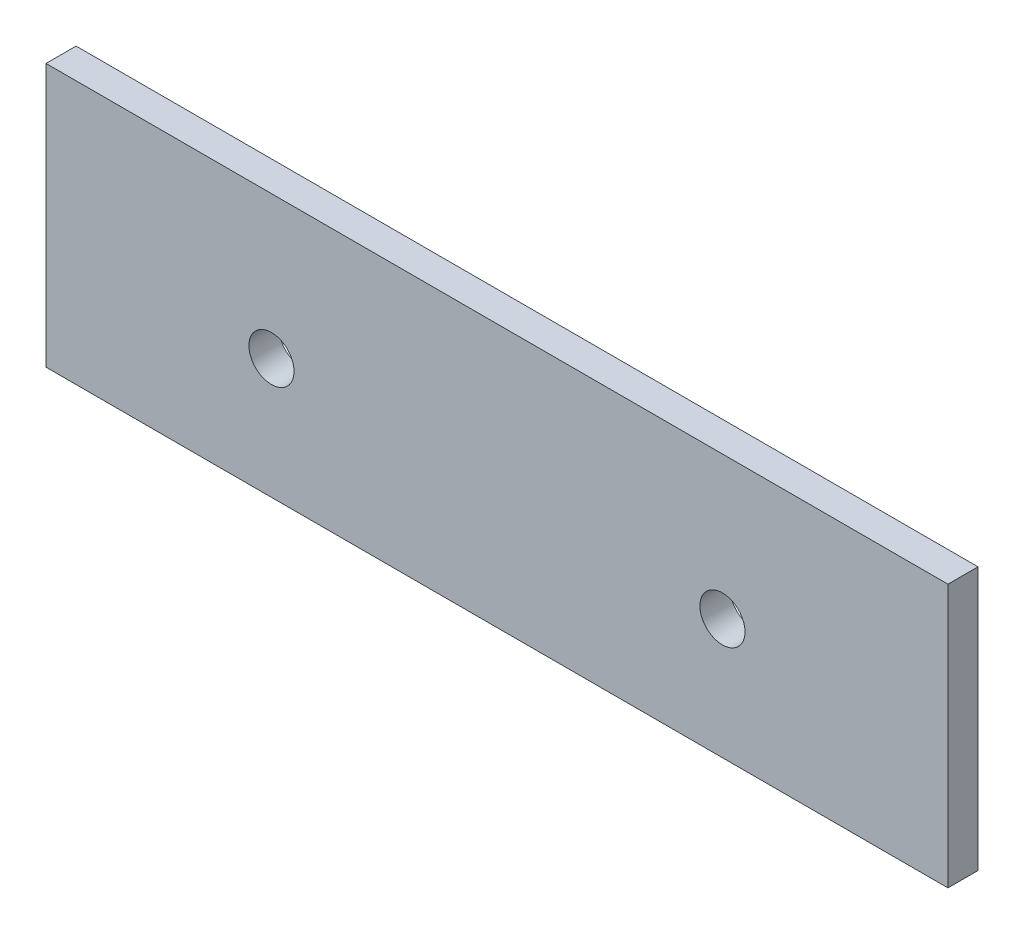
from build123d import *

# Parameters (mm, degrees)
CROQUIS1_W              = 60
CROQUIS1_H              = 17.5
SALIENTE_EXTRUIR1_DEPTH = 2
CROQUIS2_R              = 1.5
CORTAR_EXTRUIR1_DEPTH   = 3


with BuildPart() as part:
    # Croquis1 → Saliente-Extruir1 (new body)
    with BuildSketch(Plane.XY):
        Rectangle(CROQUIS1_W, CROQUIS1_H)
    extrude(amount=SALIENTE_EXTRUIR1_DEPTH)

    # Croquis2 → Cortar-Extruir1 (cut, through all)
    with BuildSketch(Plane(origin=(0, 0, 0), x_dir=(-1, 0, 0), z_dir=(0, 0, -1))):
        with Locations((15, -0.75)):
            Circle(CROQUIS2_R)
        with Locations((-15, -0.75)):
            Circle(CROQUIS2_R)
    extrude(amount=-CORTAR_EXTRUIR1_DEPTH, mode=Mode.SUBTRACT)


solid = part.part
